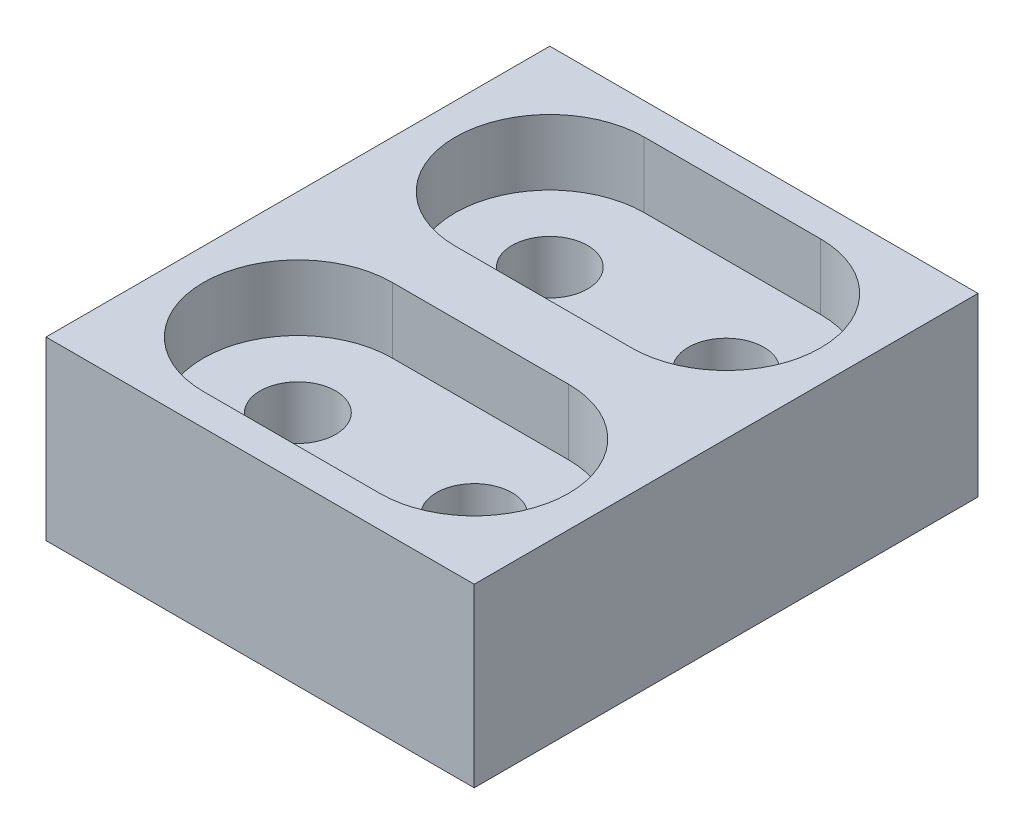
from build123d import *

# Parameters (mm, degrees)
SKETCH1_W           = 17
SKETCH1_H           = 20
SKETCH1_R           = 1.5
BOSS_EXTRUDE1_DEPTH = 7
SKETCH2_R           = 1.5
CUT_EXTRUDE6_DEPTH  = 2.6


with BuildPart() as part:
    # Sketch1 → Boss-Extrude1 (new body)
    with BuildSketch(Plane(origin=(0, 0, 0), x_dir=(1, 0, 0), z_dir=(0, 1, 0))):
        with Locations((-3.5, -5)):
            Rectangle(SKETCH1_W, SKETCH1_H)
        Circle(SKETCH1_R, mode=Mode.SUBTRACT)
        with Locations((-7, -10)):
            Circle(SKETCH1_R, mode=Mode.SUBTRACT)
        with Locations((-7, 0)):
            Circle(SKETCH1_R, mode=Mode.SUBTRACT)
        with Locations((0, -10)):
            Circle(SKETCH1_R, mode=Mode.SUBTRACT)
    extrude(amount=BOSS_EXTRUDE1_DEPTH)

    # Sketch2 → Cut-Extrude6 (cut)
    with BuildSketch(Plane(origin=(0, 7, 0), x_dir=(1, 0, 0), z_dir=(0, 1, 0))):
        with BuildLine():
            Line((-7, -13.75), (0, -13.75))
            ThreePointArc((0, -13.75), (3.75, -10), (0, -6.25))
            Line((0, -6.25), (-7, -6.25))
            ThreePointArc((-7, -6.25), (-10.75, -10), (-7, -13.75))
        make_face()
        with Locations((-7, -10)):
            Circle(SKETCH2_R, mode=Mode.SUBTRACT)
        with Locations((0, -10)):
            Circle(SKETCH2_R, mode=Mode.SUBTRACT)
        with BuildLine():
            ThreePointArc((-7, 3.75), (-10.75, 0), (-7, -3.75))
            Line((-7, -3.75), (0, -3.75))
            ThreePointArc((0, -3.75), (3.75, 0), (0, 3.75))
            Line((0, 3.75), (-7, 3.75))
        make_face()
        with Locations((-7, 0)):
            Circle(SKETCH2_R, mode=Mode.SUBTRACT)
        Circle(SKETCH2_R, mode=Mode.SUBTRACT)
    extrude(amount=-CUT_EXTRUDE6_DEPTH, mode=Mode.SUBTRACT)


solid = part.part
